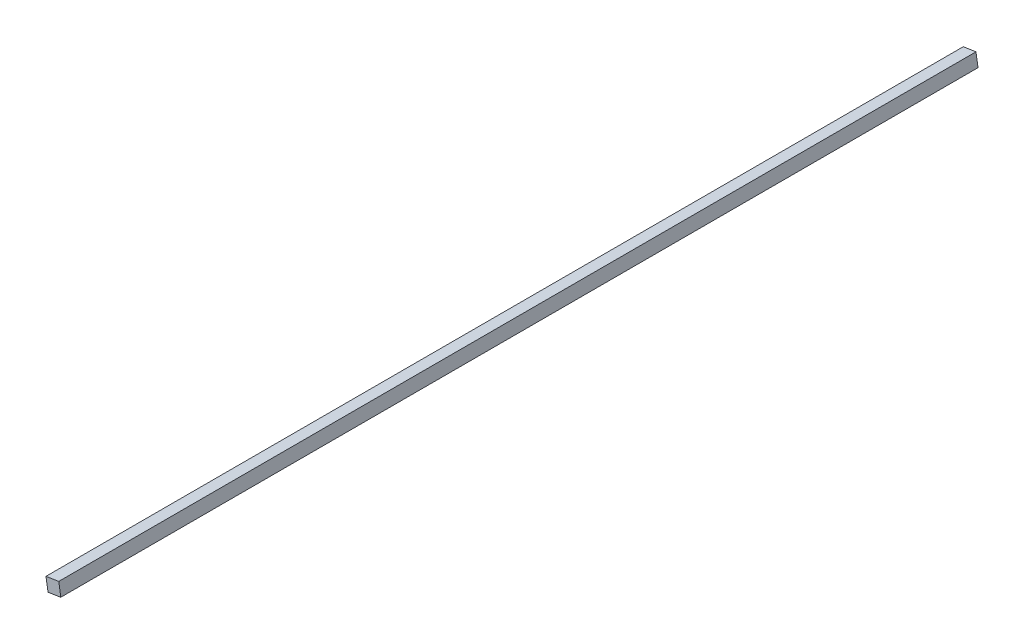
from build123d import *

# Parameters (mm, degrees)
BOSS_EXTRUDE1_DEPTH = 203.2


with BuildPart() as part:
    # Sketch1 → Boss-Extrude1 (new body)
    with BuildSketch(Plane.XY):
        Polygon((1.636246548, -1.193753452), (1.193753452, 1.636246548), (-1.636246548, 1.193753452), (-1.193753452, -1.636246548), align=None)
    extrude(amount=BOSS_EXTRUDE1_DEPTH)


solid = part.part
